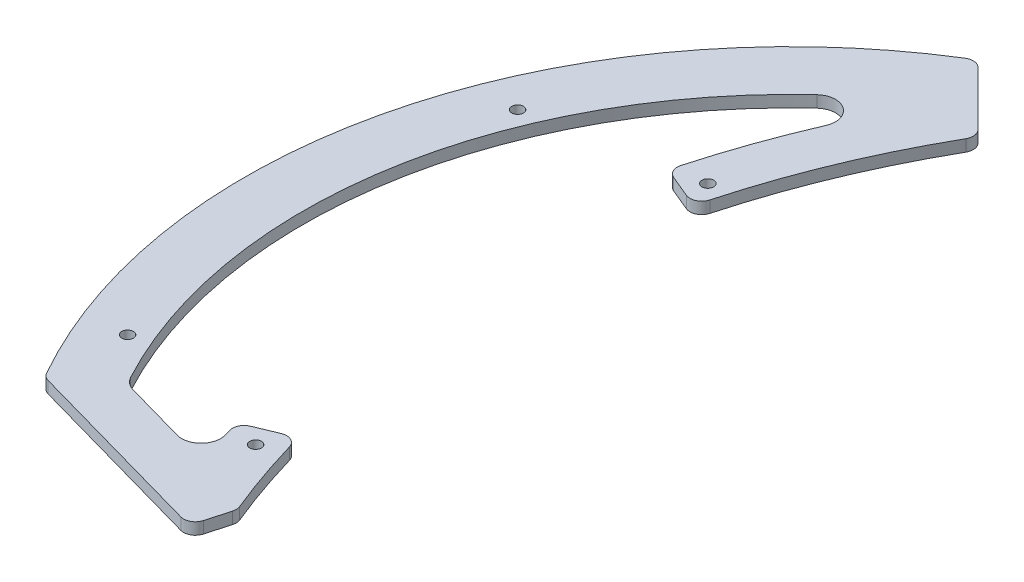
from build123d import *

# Parameters (mm, degrees)
SKETCH1_R               = 140
BOSS_EXTRUDE1_DEPTH     = 3
CUT_EXTRUDE1_REACH      = 5
CUT_EXTRUDE3_REACH      = 5
SKETCH19_R              = 1.5
CUT_EXTRUDE10_REACH     = 5
SKETCH25_R              = 1.5
CUT_EXTRUDE4_REACH      = 5
FILLET2_R               = 10
CUT_EXTRUDE8_DEPTH      = 1
CUT_EXTRUDE8_DEPTH_BACK = 4
CUT_EXTRUDE9_REACH      = 5
FILLET4_R               = 5
FILLET5_R               = 3


with BuildPart() as part:
    # Sketch1 → Boss-Extrude1 (new body)
    with BuildSketch(Plane(origin=(0, 0, 0), x_dir=(1, 0, 0), z_dir=(0, 1, 0))):
        Circle(SKETCH1_R)
    extrude(amount=BOSS_EXTRUDE1_DEPTH)

    # Sketch17 → Cut-Extrude1 (cut, up to next)
    with BuildSketch(Plane.XZ, mode=Mode.PRIVATE) as cut_extrude1_sk1:
        Polygon((-50, 90), (-121.24355653, 70), (-121.24355653, 140), (121.24355653, 140), (121.24355653, 70), (50, 90), align=None)
    cut_extrude1_tool1 = extrude(cut_extrude1_sk1.sketch, amount=-CUT_EXTRUDE1_REACH, mode=Mode.PRIVATE) & part.part
    add(cut_extrude1_tool1.solids().sort_by_distance((0, 0, 111.669853))[0], mode=Mode.SUBTRACT)

    # Sketch19 → Cut-Extrude3 (cut, up to next)
    with BuildSketch(Plane(origin=(0, 3, 0), x_dir=(1, 0, 0), z_dir=(0, 1, 0)), mode=Mode.PRIVATE) as cut_extrude3_sk1:
        with Locations((-79.195959493, -57.982756057)):
            Circle(SKETCH19_R)
    cut_extrude3_tool1 = extrude(cut_extrude3_sk1.sketch, amount=-CUT_EXTRUDE3_REACH, mode=Mode.PRIVATE) & part.part
    add(cut_extrude3_tool1.solids().sort_by_distance((-79.195959, 3, 57.982756))[0], mode=Mode.SUBTRACT)
    # Sketch19 → Cut-Extrude3 (cut, up to next)
    with BuildSketch(Plane(origin=(0, 3, 0), x_dir=(1, 0, 0), z_dir=(0, 1, 0)), mode=Mode.PRIVATE) as cut_extrude3_sk2:
        with Locations((-79.195959493, 57.982756057)):
            Circle(SKETCH19_R)
    cut_extrude3_tool2 = extrude(cut_extrude3_sk2.sketch, amount=-CUT_EXTRUDE3_REACH, mode=Mode.PRIVATE) & part.part
    add(cut_extrude3_tool2.solids().sort_by_distance((-79.195959, 3, -57.982756))[0], mode=Mode.SUBTRACT)
    # Sketch19 → Cut-Extrude3 (cut, up to next)
    with BuildSketch(Plane(origin=(0, 3, 0), x_dir=(1, 0, 0), z_dir=(0, 1, 0)), mode=Mode.PRIVATE) as cut_extrude3_sk3:
        with Locations((79.195959493, 57.982756057)):
            Circle(SKETCH19_R)
    cut_extrude3_tool3 = extrude(cut_extrude3_sk3.sketch, amount=-CUT_EXTRUDE3_REACH, mode=Mode.PRIVATE) & part.part
    add(cut_extrude3_tool3.solids().sort_by_distance((79.195959, 3, -57.982756))[0], mode=Mode.SUBTRACT)
    # Sketch19 → Cut-Extrude3 (cut, up to next)
    with BuildSketch(Plane(origin=(0, 3, 0), x_dir=(1, 0, 0), z_dir=(0, 1, 0)), mode=Mode.PRIVATE) as cut_extrude3_sk4:
        with Locations((79.195959493, -57.982756057)):
            Circle(SKETCH19_R)
    cut_extrude3_tool4 = extrude(cut_extrude3_sk4.sketch, amount=-CUT_EXTRUDE3_REACH, mode=Mode.PRIVATE) & part.part
    add(cut_extrude3_tool4.solids().sort_by_distance((79.195959, 3, 57.982756))[0], mode=Mode.SUBTRACT)
    # Sketch19 → Cut-Extrude3 (cut, up to next)
    with BuildSketch(Plane(origin=(0, 3, 0), x_dir=(1, 0, 0), z_dir=(0, 1, 0)), mode=Mode.PRIVATE) as cut_extrude3_sk5:
        with Locations((-57.982756057, 79.195959493)):
            Circle(SKETCH19_R)
    cut_extrude3_tool5 = extrude(cut_extrude3_sk5.sketch, amount=-CUT_EXTRUDE3_REACH, mode=Mode.PRIVATE) & part.part
    add(cut_extrude3_tool5.solids().sort_by_distance((-57.982756, 3, -79.195959))[0], mode=Mode.SUBTRACT)
    # Sketch19 → Cut-Extrude3 (cut, up to next)
    with BuildSketch(Plane(origin=(0, 3, 0), x_dir=(1, 0, 0), z_dir=(0, 1, 0)), mode=Mode.PRIVATE) as cut_extrude3_sk6:
        with Locations((57.982756057, 79.195959493)):
            Circle(SKETCH19_R)
    cut_extrude3_tool6 = extrude(cut_extrude3_sk6.sketch, amount=-CUT_EXTRUDE3_REACH, mode=Mode.PRIVATE) & part.part
    add(cut_extrude3_tool6.solids().sort_by_distance((57.982756, 3, -79.195959))[0], mode=Mode.SUBTRACT)
    # Sketch19 → Cut-Extrude3 (cut, up to next)
    with BuildSketch(Plane(origin=(0, 3, 0), x_dir=(1, 0, 0), z_dir=(0, 1, 0)), mode=Mode.PRIVATE) as cut_extrude3_sk7:
        with Locations((57.982756057, -79.195959493)):
            Circle(SKETCH19_R)
    cut_extrude3_tool7 = extrude(cut_extrude3_sk7.sketch, amount=-CUT_EXTRUDE3_REACH, mode=Mode.PRIVATE) & part.part
    add(cut_extrude3_tool7.solids().sort_by_distance((57.982756, 3, 79.195959))[0], mode=Mode.SUBTRACT)
    # Sketch19 → Cut-Extrude3 (cut, up to next)
    with BuildSketch(Plane(origin=(0, 3, 0), x_dir=(1, 0, 0), z_dir=(0, 1, 0)), mode=Mode.PRIVATE) as cut_extrude3_sk8:
        with Locations((-57.982756057, -79.195959493)):
            Circle(SKETCH19_R)
    cut_extrude3_tool8 = extrude(cut_extrude3_sk8.sketch, amount=-CUT_EXTRUDE3_REACH, mode=Mode.PRIVATE) & part.part
    add(cut_extrude3_tool8.solids().sort_by_distance((-57.982756, 3, 79.195959))[0], mode=Mode.SUBTRACT)

    # Sketch25 → Cut-Extrude10 (cut, up to next)
    with BuildSketch(Plane(origin=(0, 3, 0), x_dir=(1, 0, 0), z_dir=(0, 1, 0)), mode=Mode.PRIVATE) as cut_extrude10_sk1:
        with Locations((-120, 50)):
            Circle(SKETCH25_R)
    cut_extrude10_tool1 = extrude(cut_extrude10_sk1.sketch, amount=-CUT_EXTRUDE10_REACH, mode=Mode.PRIVATE) & part.part
    add(cut_extrude10_tool1.solids().sort_by_distance((-120, 3, -50))[0], mode=Mode.SUBTRACT)
    # Sketch25 → Cut-Extrude10 (cut, up to next)
    with BuildSketch(Plane(origin=(0, 3, 0), x_dir=(1, 0, 0), z_dir=(0, 1, 0)), mode=Mode.PRIVATE) as cut_extrude10_sk2:
        with Locations((-120, -50)):
            Circle(SKETCH25_R)
    cut_extrude10_tool2 = extrude(cut_extrude10_sk2.sketch, amount=-CUT_EXTRUDE10_REACH, mode=Mode.PRIVATE) & part.part
    add(cut_extrude10_tool2.solids().sort_by_distance((-120, 3, 50))[0], mode=Mode.SUBTRACT)

    # Sketch20 → Cut-Extrude4 (cut, up to next)
    with BuildSketch(Plane(origin=(0, 3, 0), x_dir=(1, 0, 0), z_dir=(0, 1, 0)), mode=Mode.PRIVATE) as cut_extrude4_sk1:
        Polygon((-501.142143979, 549.208792138), (-72, 120.066648158), (-50, 98.066648158), (50, 98.066648158), (72, 120.066648158), (501.142143979, 549.208792138), (501.142143979, 1763.00607254), (-501.142143979, 1763.00607254), align=None)
    cut_extrude4_tool1 = extrude(cut_extrude4_sk1.sketch, amount=-CUT_EXTRUDE4_REACH, mode=Mode.PRIVATE) & part.part
    add(cut_extrude4_tool1.solids().sort_by_distance((0, 3, -1025.283687))[0], mode=Mode.SUBTRACT)

    # Fillet2
    fillet2_edges = [part.edges().sort_by_distance(p)[0] for p in [
        (50, 1.5, -98.066648158),
        (-50, 1.5, -98.066648158),
    ]]
    fillet(fillet2_edges, radius=FILLET2_R)

    # Sketch23 → Cut-Extrude8 (cut, two sides)
    with BuildSketch(Plane(origin=(0, 3, 0), x_dir=(1, 0, 0), z_dir=(0, 1, 0))) as cut_extrude8_sk:
        with BuildLine():
            Line((257.25555619, 635.882543767), (-54.933351842, 103))
            ThreePointArc((-54.933351842, 103), (-81.898962794, 15.574433529), (-67.110613718, -74.712213204))
            Line((-67.110613718, -74.712213204), (-73.189737717, -96.367133919))
            Line((-73.189737717, -96.367133919), (-240.113193325, -690.978166206))
            Line((-240.113193325, -690.978166206), (916.492938423, -1124.527627053))
            Line((916.492938423, -1124.527627053), (1413.861687938, 202.33308292))
            Line((1413.861687938, 202.33308292), (257.25555619, 635.882543767))
        make_face()
    extrude(amount=CUT_EXTRUDE8_DEPTH, mode=Mode.SUBTRACT)
    extrude(cut_extrude8_sk.sketch, amount=-CUT_EXTRUDE8_DEPTH_BACK, mode=Mode.SUBTRACT)

    # Sketch24 → Cut-Extrude9 (cut, up to next)
    with BuildSketch(Plane(origin=(0, 3, 0), x_dir=(1, 0, 0), z_dir=(0, 1, 0)), mode=Mode.PRIVATE) as cut_extrude9_sk1:
        with BuildLine():
            Line((-87.357146899, 55.966584143), (-76.169199175, 51.304939258))
            Line((-76.169199175, 51.304939258), (-75.263305358, -50.927483501))
            Line((-75.263305358, -50.927483501), (-86.425648637, -55.578459868))
            ThreePointArc((-86.425648637, -55.578459868), (-84.491324796, -62.048707618), (-82.351900579, -68.454063088))
            Line((-82.351900579, -68.454063088), (-109.142815319, -60.933126165))
            ThreePointArc((-109.142815319, -60.933126165), (-121.247849947, 30.39669198), (-67.489752352, 105.2147011))
            ThreePointArc((-67.489752352, 105.2147011), (-78.971583679, 81.215182034), (-87.357146899, 55.966584143))
        make_face()
    cut_extrude9_tool1 = extrude(cut_extrude9_sk1.sketch, amount=-CUT_EXTRUDE9_REACH, mode=Mode.PRIVATE) & part.part
    add(cut_extrude9_tool1.solids().sort_by_distance((-97.439624, 3, -6.929648))[0], mode=Mode.SUBTRACT)

    # Fillet4
    fillet4_edges = [part.edges().sort_by_distance(p)[0] for p in [
        (-109.142815319, 1.5, 60.933126165),
        (-67.489752352, 1.5, -105.2147011),
        (-82.351900579, 1.5, 68.454063088),
    ]]
    fillet(fillet4_edges, radius=FILLET4_R)

    # Fillet5
    fillet5_edges = [part.edges().sort_by_distance(p)[0] for p in [
        (-87.357146899, 1.5, -55.966584143),
        (-76.169199175, 1.5, -51.304939258),
        (-75.263305358, 1.5, 50.927483501),
        (-86.425648637, 1.5, 55.578459868),
        (-121.24355653, 1.5, 70),
        (-72, 1.5, -120.066648158),
        (-54.933351842, 1.5, -103),
        (-69.838855295, 1.5, 84.430694855),
        (-67.110613718, 1.5, 74.712213204),
    ]]
    fillet(fillet5_edges, radius=FILLET5_R)


solid = part.part
